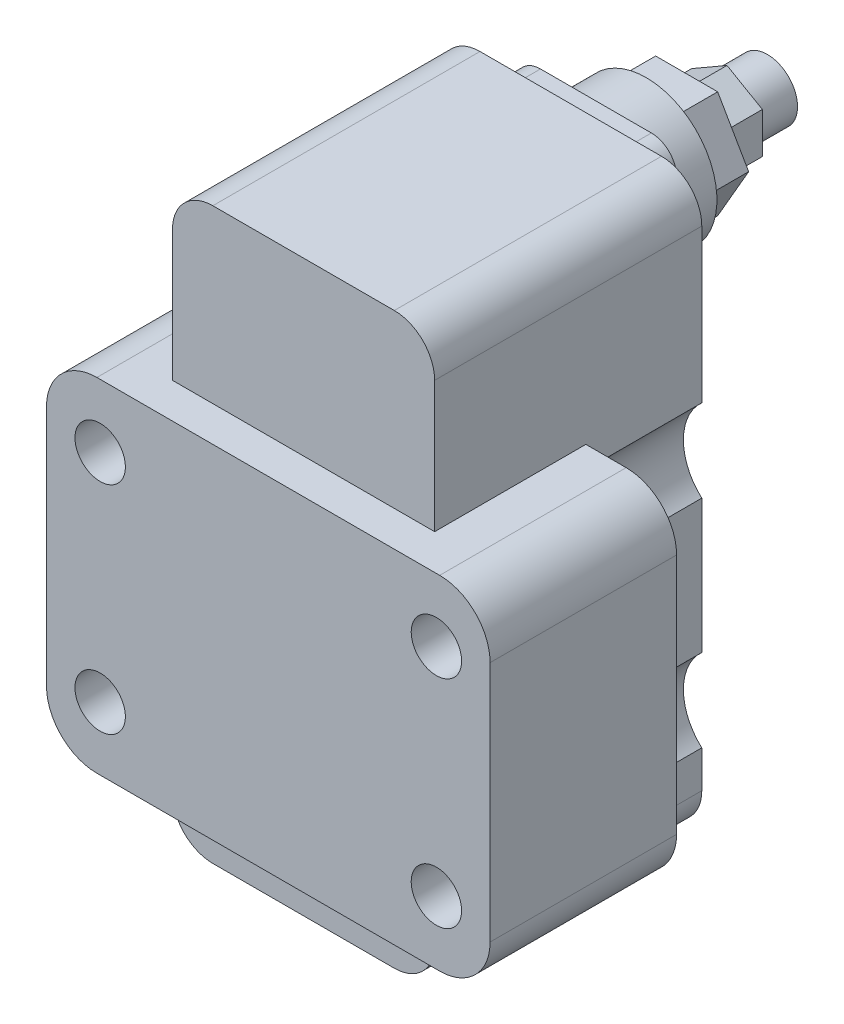
from build123d import *

# Parameters (mm, degrees)
SKETCH_1_W          = 88
SKETCH_1_H          = 68
EXTRUDE_1_DEPTH     = 37
SKETCH_2_W          = 52
SKETCH_2_H          = 113
EXTRUDE_2_DEPTH     = 60
SKETCH_3_R          = 5
CUT_EXTRUDE_1_DEPTH = 60
CUT_EXTRUDE_2_DEPTH = 23
SKETCH_5_OUTSIDE_W  = 121.056
SKETCH_5_OUTSIDE_H  = 146.056
CUT_EXTRUDE_3_DEPTH = 38
SKETCH_7_W          = 52
SKETCH_7_H          = 34
SKETCH_7_H_2        = 11
EXTRUDE_3_DEPTH     = 30
FILLET_1_R          = 8
SKETCH_8_W          = 32
SKETCH_8_H          = 30
EXTRUDE_4_DEPTH     = 5
SKETCH_9_R          = 14
EXTRUDE_5_DEPTH     = 10
EXTRUDE_6_DEPTH     = 8
FILLET_2_R          = 5
EXTRUDE_7_DEPTH     = 8
SKETCH_12_R         = 6
EXTRUDE_8_DEPTH     = 8


with BuildPart() as part:
    # 草图1 → 凸台-拉伸1 (new body)
    with BuildSketch(Plane.XY):
        Rectangle(SKETCH_1_W, SKETCH_1_H)
    extrude(amount=EXTRUDE_1_DEPTH)

    # 草图2 → 凸台-拉伸2 (add)
    with BuildSketch(Plane.XY.offset(37)):
        with Locations((0, 11.5)):
            Rectangle(SKETCH_2_W, SKETCH_2_H)
    extrude(amount=-EXTRUDE_2_DEPTH)

    # 草图3 → 切除-拉伸1 (cut)
    with BuildSketch(Plane(origin=(0, 0, -23), x_dir=(-1, 0, 0), z_dir=(0, 0, -1))):
        with Locations((-33.35, 21.45)):
            Circle(SKETCH_3_R)
        with Locations((33.35, 21.45)):
            Circle(SKETCH_3_R)
        with Locations((33.35, -21.45)):
            Circle(SKETCH_3_R)
        with Locations((-33.35, -21.45)):
            Circle(SKETCH_3_R)
    extrude(amount=-CUT_EXTRUDE_1_DEPTH, mode=Mode.SUBTRACT)

    # 草图4 → 切除-拉伸2 (cut)
    with BuildSketch(Plane(origin=(0, 0, -23), x_dir=(-1, 0, 0), z_dir=(0, 0, -1))):
        with BuildLine():
            Line((-26, 29.63397825), (-26, 13.26602175))
            ThreePointArc((-26, 13.26602175), (-22.35, 21.45), (-26, 29.63397825))
        make_face()
        with BuildLine():
            Line((26, 29.63397825), (26, 13.26602175))
            ThreePointArc((26, 13.26602175), (22.35, 21.45), (26, 29.63397825))
        make_face()
        with BuildLine():
            Line((26, -13.26602175), (26, -29.63397825))
            ThreePointArc((26, -29.63397825), (22.35, -21.45), (26, -13.26602175))
        make_face()
        with BuildLine():
            Line((-26, -13.26602175), (-26, -29.63397825))
            ThreePointArc((-26, -29.63397825), (-22.35, -21.45), (-26, -13.26602175))
        make_face()
    extrude(amount=-CUT_EXTRUDE_2_DEPTH, mode=Mode.SUBTRACT)

    # 草图5 outside → 切除-拉伸3 (cut, through all)
    with BuildSketch(Plane(origin=(0, 0, 0), x_dir=(-1, 0, 0), z_dir=(0, 0, -1))):
        with Locations((0, 11.5)):
            Rectangle(SKETCH_5_OUTSIDE_W, SKETCH_5_OUTSIDE_H)
        with BuildLine():
            Line((-34, 34), (34, 34))
            ThreePointArc((34, 34), (41.071067812, 31.071067812), (44, 24))
            Line((44, 24), (44, -24))
            ThreePointArc((44, -24), (41.071067812, -31.071067812), (34, -34))
            Line((34, -34), (-34, -34))
            ThreePointArc((-34, -34), (-41.071067812, -31.071067812), (-44, -24))
            Line((-44, -24), (-44, 24))
            ThreePointArc((-44, 24), (-41.071067812, 31.071067812), (-34, 34))
        make_face(mode=Mode.SUBTRACT)
    extrude(amount=-CUT_EXTRUDE_3_DEPTH, mode=Mode.SUBTRACT)

    # 草图7 → 凸台-拉伸3 (add)
    with BuildSketch(Plane.XY):
        with Locations((0, 51)):
            Rectangle(SKETCH_7_W, SKETCH_7_H)
        with Locations((0, -39.5)):
            Rectangle(SKETCH_7_W, SKETCH_7_H_2)
    extrude(amount=EXTRUDE_3_DEPTH)

    # 圆角1
    fillet_1_edges = [part.edges().sort_by_distance(p)[0] for p in [
        (-26, -45, 3.5),
        (26, 68, 3.5),
        (-26, 68, 3.5),
        (26, -45, 3.5),
    ]]
    fillet(fillet_1_edges, radius=FILLET_1_R)

    # 草图8 → 凸台-拉伸4 (add)
    with BuildSketch(Plane(origin=(0, 0, -23), x_dir=(-1, 0, 0), z_dir=(0, 0, -1))):
        with Locations((0, 51)):
            Rectangle(SKETCH_8_W, SKETCH_8_H)
    extrude(amount=EXTRUDE_4_DEPTH)

    # 草图9 → 凸台-拉伸5 (add)
    with BuildSketch(Plane(origin=(0, 0, -28), x_dir=(-1, 0, 0), z_dir=(0, 0, -1))):
        with Locations((0, 51)):
            Circle(SKETCH_9_R)
    extrude(amount=EXTRUDE_5_DEPTH)

    # 草图10 → 凸台-拉伸6 (add)
    with BuildSketch(Plane(origin=(0, 0, -38), x_dir=(-1, 0, 0), z_dir=(0, 0, -1))):
        Polygon((-6.149615956, 61.651447283), (-12.299231913, 51), (-6.149615956, 40.348552717), (6.149615956, 40.348552717), (12.299231913, 51), (6.149615956, 61.651447283), align=None)
    extrude(amount=EXTRUDE_6_DEPTH)

    # 圆角2
    fillet_2_edges = [part.edges().sort_by_distance(p)[0] for p in [
        (16, 66, -25.5),
        (16, 36, -25.5),
        (-16, 36, -25.5),
        (-16, 66, -25.5),
    ]]
    fillet(fillet_2_edges, radius=FILLET_2_R)

    # 草图11 → 凸台-拉伸7 (add)
    with BuildSketch(Plane(origin=(0, 0, -46), x_dir=(-1, 0, 0), z_dir=(0, 0, -1))):
        Polygon((0, 42.898459123), (7.016140209, 46.949229562), (7.016140209, 55.050770438), (0, 59.101540877), (-7.016140209, 55.050770438), (-7.016140209, 46.949229562), align=None)
    extrude(amount=EXTRUDE_7_DEPTH)

    # 草图12 → 凸台-拉伸8 (add)
    with BuildSketch(Plane(origin=(0, 0, -54), x_dir=(-1, 0, 0), z_dir=(0, 0, -1))):
        with Locations((0, 51)):
            Circle(SKETCH_12_R)
    extrude(amount=EXTRUDE_8_DEPTH)


solid = part.part
